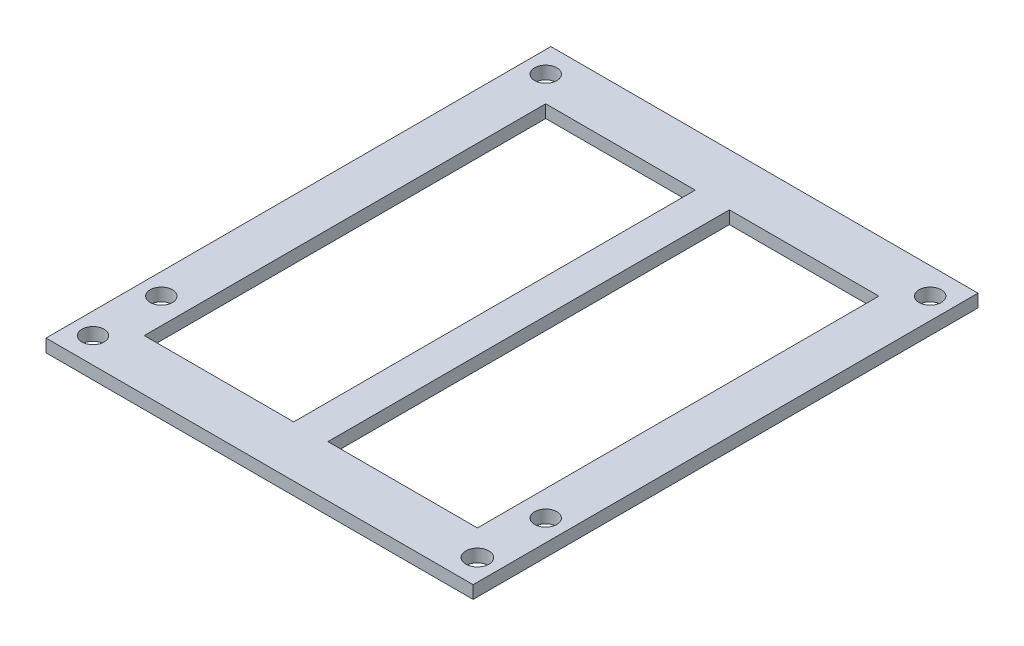
from build123d import *

# Parameters (mm, degrees)
SKETCH_1_R      = 1.35
SKETCH_1_R_2    = 1.3
SKETCH_1_W      = 17.5
SKETCH_1_H      = 47
EXTRUDE_1_DEPTH = 1.5


with BuildPart() as part:
    # 草图1 → 凸台-拉伸1 (new body)
    with BuildSketch(Plane(origin=(0, 0, 0), x_dir=(1, 0, 0), z_dir=(0, 1, 0))):
        Polygon((25, 11), (25, -3), (-25, -3), (-25, 11), (-25, 56.10335237), (25, 56.10335237), align=None)
        with Locations((22.5, 0)):
            Circle(SKETCH_1_R, mode=Mode.SUBTRACT)
        with Locations((-22.5, 0)):
            Circle(SKETCH_1_R_2, mode=Mode.SUBTRACT)
        with Locations((-22.5, 8)):
            Circle(SKETCH_1_R_2, mode=Mode.SUBTRACT)
        with Locations((22.5, 8)):
            Circle(SKETCH_1_R_2, mode=Mode.SUBTRACT)
        with Locations((-22.5, 53)):
            Circle(SKETCH_1_R_2, mode=Mode.SUBTRACT)
        with Locations((22.5, 53)):
            Circle(SKETCH_1_R_2, mode=Mode.SUBTRACT)
        with Locations((10.75, 26.5)):
            Rectangle(SKETCH_1_W, SKETCH_1_H, mode=Mode.SUBTRACT)
        with Locations((-10.75, 26.5)):
            Rectangle(SKETCH_1_W, SKETCH_1_H, mode=Mode.SUBTRACT)
    extrude(amount=EXTRUDE_1_DEPTH)


solid = part.part
